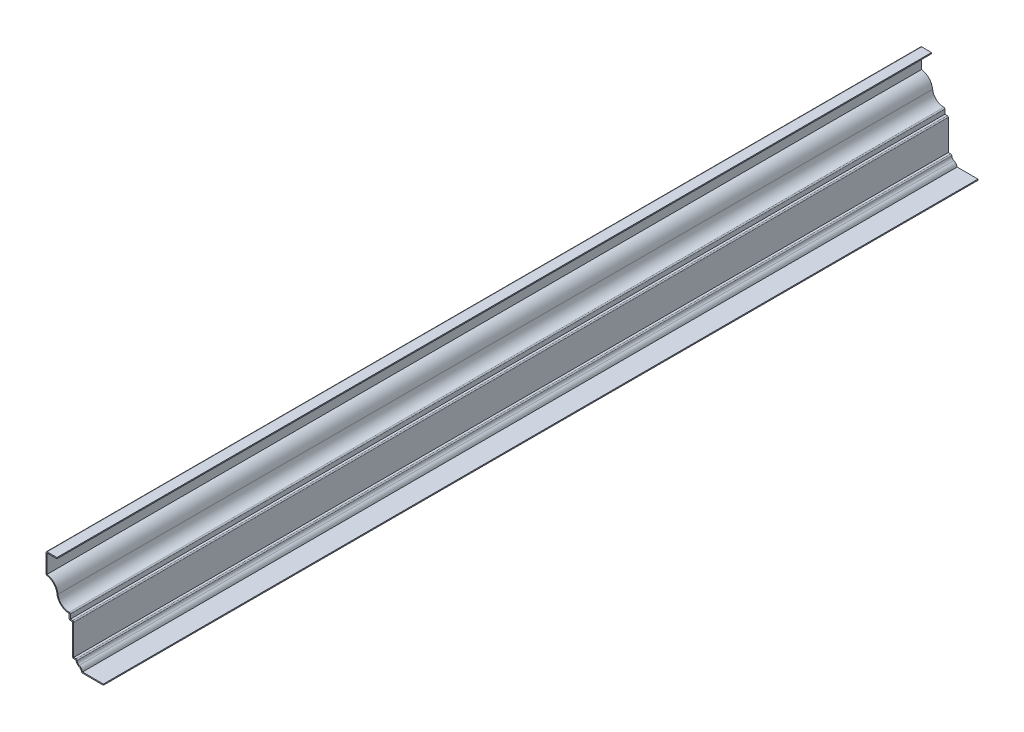
from build123d import *

# Parameters (mm, degrees)
EXTRUDE_THIN1_DEPTH = 1016
FILLET1_R           = 1.27


with BuildPart() as part:
    # Sketch1 → Extrude-Thin1 (new body)
    with BuildSketch(Plane.XY):
        with BuildLine():
            Line((0, 0), (-25.4, 0))
            ThreePointArc((-25.4, 0), (-26.266516, 2.861906), (-28.575, 4.7625))
            ThreePointArc((-28.575, 4.7625), (-30.883484, 6.663094), (-31.75, 9.525))
            Line((-31.75, 9.525), (-35.71875, 9.525))
            Line((-35.71875, 9.525), (-35.71875, 46.0375))
            Line((-35.71875, 46.0375), (-39.6875, 46.0375))
            Line((-39.6875, 46.0375), (-39.6875, 52.3875))
            ThreePointArc((-39.6875, 52.3875), (-49.260127, 56.036408), (-53.975, 65.131445))
            ThreePointArc((-53.975, 65.131445), (-58.111252, 73.680907), (-66.675, 77.7875))
            Line((-66.675, 77.7875), (-66.675, 101.6))
            Line((-66.675, 101.6), (-53.975, 101.6))
            Line((-53.975, 101.6), (-53.975, 100.33))
            Line((-53.975, 100.33), (-65.405, 100.33))
            Line((-65.405, 100.33), (-65.405, 78.882323))
            ThreePointArc((-65.405, 78.882323), (-56.817633, 74.169998), (-52.713255, 65.276013))
            ThreePointArc((-52.713255, 65.276013), (-47.930054, 56.572496), (-38.4175, 53.719154))
            Line((-38.4175, 53.719154), (-38.4175, 47.3075))
            Line((-38.4175, 47.3075), (-34.44875, 47.3075))
            Line((-34.44875, 47.3075), (-34.44875, 10.795))
            Line((-34.44875, 10.795), (-30.26681, 10.795))
            ThreePointArc((-30.26681, 10.795), (-30.139289, 7.933077), (-28.086538, 5.934808))
            ThreePointArc((-28.086538, 5.934808), (-25.590211, 4.079739), (-24.25668, 1.27))
            Line((-24.25668, 1.27), (0, 1.27))
            Line((0, 1.27), (0, 0))
        make_face()
    extrude(amount=-EXTRUDE_THIN1_DEPTH)

    # Fillet1
    fillet1_edges = [part.edges().sort_by_distance(p)[0] for p in [
        (-38.4175, 53.719154, -508),
        (-34.44875, 47.3075, -508),
        (-30.26681, 10.795, -508),
        (-25.4, 0, -508),
        (-35.71875, 9.525, -508),
        (-39.6875, 46.0375, -508),
        (-66.675, 77.7875, -508),
        (-66.675, 101.6, -508),
    ]]
    fillet(fillet1_edges, radius=FILLET1_R)


solid = part.part
